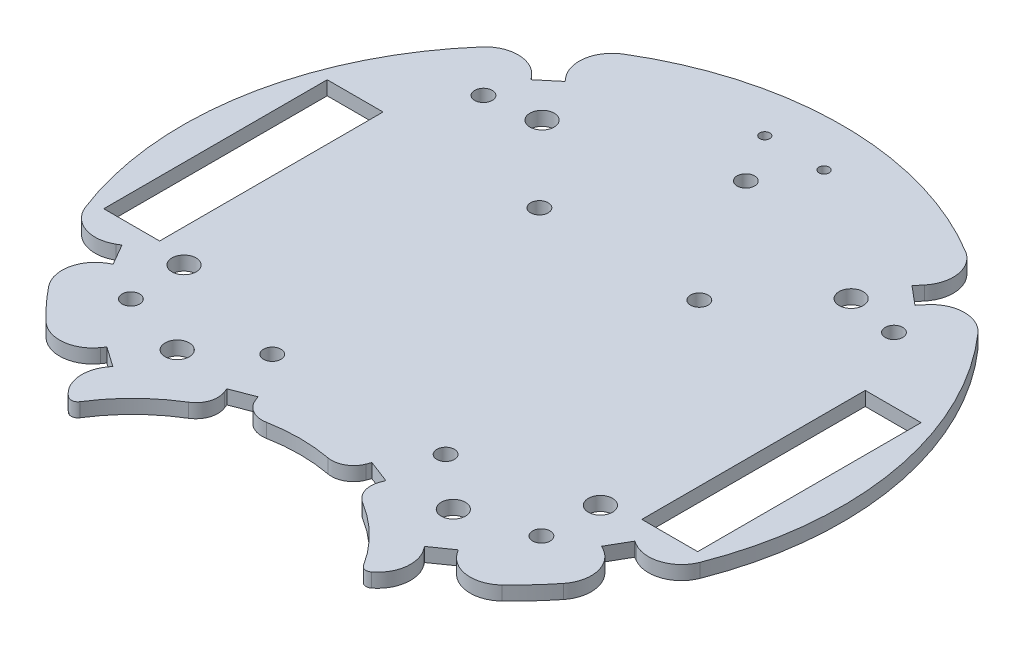
from build123d import *

# Parameters (mm, degrees)
SKETCH1_R           = 2
SKETCH1_R_2         = 1.143
SKETCH1_R_3         = 2.75
SKETCH1_W           = 12.7
SKETCH1_H           = 50.8
BOSS_EXTRUDE1_DEPTH = 3.175


with BuildPart() as part:
    # Sketch1 → Boss-Extrude1 (new body)
    with BuildSketch(Plane(origin=(0, 0, 0), x_dir=(1, 0, 0), z_dir=(0, 1, 0))):
        with BuildLine():
            Line((-36.014757408, -56.228882693), (-35.441180971, -55.409730648))
            Line((-35.441180971, -55.409730648), (-39.946517215, -52.255060249))
            Line((-39.946517215, -52.255060249), (-40.520093651, -53.074212293))
            ThreePointArc((-40.520093651, -53.074212293), (-45.927580176, -56.23617342), (-51.848593315, -54.191543356))
            ThreePointArc((-51.848593315, -54.191543356), (-55.295899374, -50.669157408), (-58.504414423, -46.927960674))
            ThreePointArc((-58.504414423, -46.927960674), (-60.025192689, -40.851285995), (-56.403972981, -35.739974078))
            Line((-56.403972981, -35.739974078), (-55.537947577, -35.239974078))
            Line((-55.537947577, -35.239974078), (-58.287686569, -30.477286437))
            Line((-58.287686569, -30.477286437), (-59.153711973, -30.977286437))
            ThreePointArc((-59.153711973, -30.977286437), (-65.390847794, -31.557698738), (-69.893013303, -27.202328787))
            ThreePointArc((-69.893013303, -27.202328787), (-73.860606951, 13.023468848), (-56.374397975, 49.466425512))
            ThreePointArc((-56.374397975, 49.466425512), (-50.654117331, 52.01932544), (-44.991624855, 49.340690033))
            Line((-44.991624855, 49.340690033), (-44.348837245, 48.57464559))
            Line((-44.348837245, 48.57464559), (-40.135592808, 52.109977443))
            Line((-40.135592808, 52.109977443), (-40.778380417, 52.876021886))
            ThreePointArc((-40.778380417, 52.876021886), (-42.433039833, 58.917628536), (-38.925607882, 64.107698843))
            ThreePointArc((-38.925607882, 64.107698843), (0, 75), (38.925607882, 64.107698843))
            ThreePointArc((38.925607882, 64.107698843), (42.433039833, 58.917628536), (40.778380417, 52.876021886))
            Line((40.778380417, 52.876021886), (39.492805198, 51.343933))
            Line((39.492805198, 51.343933), (43.706049635, 47.808601147))
            Line((43.706049635, 47.808601147), (44.991624855, 49.340690033))
            ThreePointArc((44.991624855, 49.340690033), (50.654117331, 52.01932544), (56.374397975, 49.466425512))
            ThreePointArc((56.374397975, 49.466425512), (73.860606951, 13.023468848), (69.893013303, -27.202328787))
            ThreePointArc((69.893013303, -27.202328787), (65.390847794, -31.557698738), (59.153711973, -30.977286437))
            Line((59.153711973, -30.977286437), (58.287686569, -30.477286437))
            Line((58.287686569, -30.477286437), (55.537947577, -35.239974078))
            Line((55.537947577, -35.239974078), (56.403972981, -35.739974078))
            ThreePointArc((56.403972981, -35.739974078), (60.025192689, -40.851285995), (58.504414423, -46.927960674))
            ThreePointArc((58.504414423, -46.927960674), (55.295899374, -50.669157408), (51.848593315, -54.191543356))
            ThreePointArc((51.848593315, -54.191543356), (45.927580176, -56.23617342), (40.520093651, -53.074212293))
            Line((40.520093651, -53.074212293), (39.946517215, -52.255060249))
            Line((39.946517215, -52.255060249), (35.441180971, -55.409730648))
            Line((35.441180971, -55.409730648), (36.014757408, -56.228882693))
            ThreePointArc((36.014757408, -56.228882693), (37.282182463, -61.682274385), (34.419720881, -66.493943628))
            ThreePointArc((34.419720881, -66.493943628), (33.243515234, -66.777434912), (32.240681933, -66.10056535))
            ThreePointArc((32.240681933, -66.10056535), (26.728650164, -59.250774979), (19.793246149, -53.846860332))
            ThreePointArc((19.793246149, -53.846860332), (17.659799789, -51.192486841), (17.721018114, -47.787557426))
            Line((17.721018114, -47.787557426), (18.078412971, -46.853604046))
            Line((18.078412971, -46.853604046), (12.941669381, -44.887932332))
            Line((12.941669381, -44.887932332), (12.584274523, -45.821885712))
            ThreePointArc((12.584274523, -45.821885712), (10.356790186, -48.397852623), (6.996351286, -48.949887413))
            ThreePointArc((6.996351286, -48.949887413), (0, -48.302004425), (-6.996351286, -48.949887413))
            ThreePointArc((-6.996351286, -48.949887413), (-10.356790186, -48.397852623), (-12.584274523, -45.821885712))
            Line((-12.584274523, -45.821885712), (-12.941669381, -44.887932332))
            Line((-12.941669381, -44.887932332), (-18.078412971, -46.853604046))
            Line((-18.078412971, -46.853604046), (-17.721018114, -47.787557426))
            ThreePointArc((-17.721018114, -47.787557426), (-17.659799789, -51.192486841), (-19.793246149, -53.846860332))
            ThreePointArc((-19.793246149, -53.846860332), (-26.728650164, -59.250774979), (-32.240681933, -66.10056535))
            ThreePointArc((-32.240681933, -66.10056535), (-33.243515234, -66.777434912), (-34.419720881, -66.493943628))
            ThreePointArc((-34.419720881, -66.493943628), (-37.282182463, -61.682274385), (-36.014757408, -56.228882693))
        make_face()
        with Locations((-18.178952795, 24.310551096)):
            Circle(SKETCH1_R, mode=Mode.SUBTRACT)
        with Locations((-46.663733983, -40.081231883)):
            Circle(SKETCH1_R, mode=Mode.SUBTRACT)
        with Locations((46.663733983, -40.081231883)):
            Circle(SKETCH1_R, mode=Mode.SUBTRACT)
        with Locations((46.663733983, 40.081231883)):
            Circle(SKETCH1_R, mode=Mode.SUBTRACT)
        with Locations((-46.663733983, 40.081231883)):
            Circle(SKETCH1_R, mode=Mode.SUBTRACT)
        with Locations((-6.731, 64.107698843)):
            Circle(SKETCH1_R_2, mode=Mode.SUBTRACT)
        with Locations((6.731, 64.107698843)):
            Circle(SKETCH1_R_2, mode=Mode.SUBTRACT)
        with Locations((-31.384508293, -44.821722961)):
            Circle(SKETCH1_R_3, mode=Mode.SUBTRACT)
        with Locations((18.178952795, 24.310551096)):
            Circle(SKETCH1_R, mode=Mode.SUBTRACT)
        with Locations((0, 53.061187965)):
            Circle(SKETCH1_R, mode=Mode.SUBTRACT)
        with Locations((-47.332350097, -27.32734507)):
            Circle(SKETCH1_R_3, mode=Mode.SUBTRACT)
        with Locations((-35.134053633, 41.871134639)):
            Circle(SKETCH1_R_3, mode=Mode.SUBTRACT)
        with Locations((-19.709430746, -34.896815973)):
            Circle(SKETCH1_R, mode=Mode.SUBTRACT)
        with Locations((35.134053633, 41.871134639)):
            Circle(SKETCH1_R_3, mode=Mode.SUBTRACT)
        with Locations((47.332350097, -27.32734507)):
            Circle(SKETCH1_R_3, mode=Mode.SUBTRACT)
        with Locations((31.384508293, -44.821722961)):
            Circle(SKETCH1_R_3, mode=Mode.SUBTRACT)
        with Locations((19.709430746, -34.896815973)):
            Circle(SKETCH1_R, mode=Mode.SUBTRACT)
        with Locations((61.164123727, 0)):
            Rectangle(SKETCH1_W, SKETCH1_H, mode=Mode.SUBTRACT)
        with Locations((-61.164123727, 0)):
            Rectangle(SKETCH1_W, SKETCH1_H, mode=Mode.SUBTRACT)
    extrude(amount=BOSS_EXTRUDE1_DEPTH)


solid = part.part
